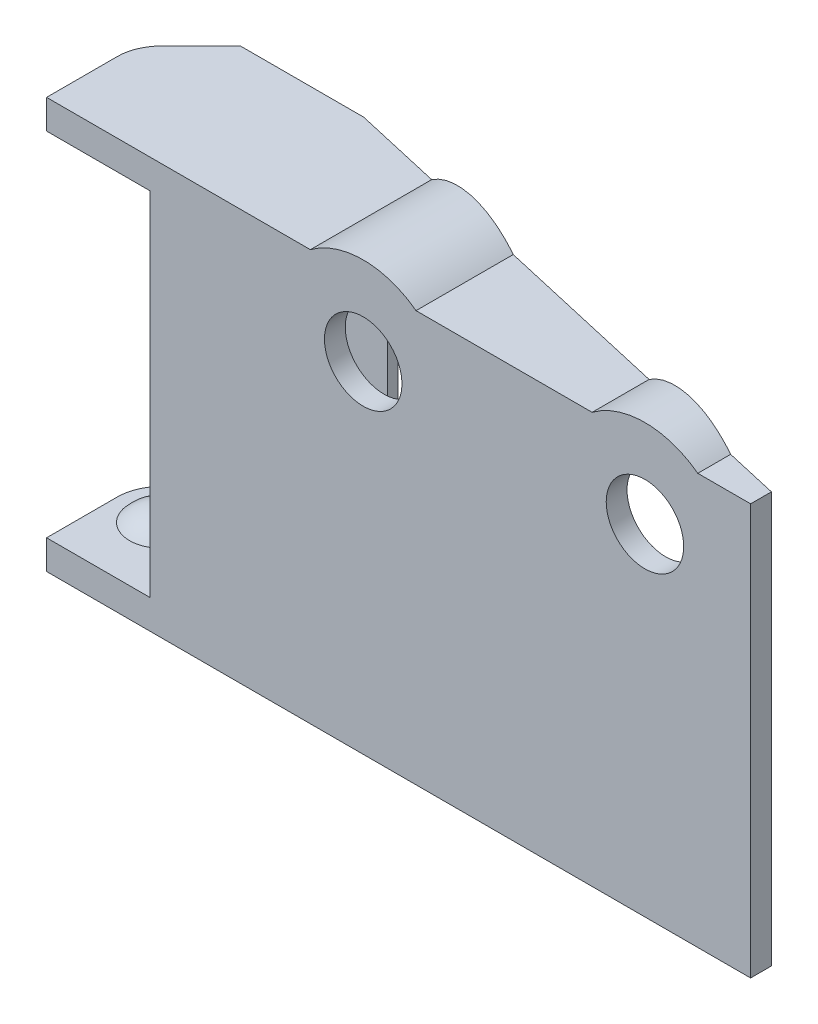
from build123d import *

# Parameters (mm, degrees)
BOSS_EXTRUDE2_DEPTH             = 2.1082
BOSS_EXTRUDE3_DEPTH             = 0.9
SKETCH13_W                      = 5.200208993
SKETCH13_H                      = 1.5
BOSS_EXTRUDE4_DEPTH             = 12.7
SKETCH16_W                      = 7.09322036
SKETCH16_H                      = 1.5
BOSS_EXTRUDE5_DEPTH             = 11.8
SKETCH17_W                      = 1.5
SKETCH17_H                      = 23.6
BOSS_EXTRUDE6_DEPTH             = 38.1
BOSS_EXTRUDE7_REACH             = 53.45
BOSS_EXTRUDE8_DEPTH             = 3.0082
CUT_EXTRUDE1_DEPTH              = 52.450131959
CUT_EXTRUDE2_REACH              = 52.338
SKETCH21_R                      = 2.794
SKETCH22_R                      = 4.572
CUT_EXTRUDE3_DEPTH              = 51.337641034
BOSS_EXTRUDE9_REACH             = 52.338
BOSS_EXTRUDE9_DIRECTION_2_DEPTH = 1.5


with BuildPart() as part:
    # Sketch6 → Boss-Extrude2 (new body)
    with BuildSketch(Plane(origin=(0, 0, 0), x_dir=(1, 0, 0), z_dir=(0, 1, 0))):
        with BuildLine():
            Line((3.1496, 3.175), (3.1496, 8.27377964))
            Line((3.1496, 8.27377964), (-5.741348421, 8.27377964))
            Line((-5.741348421, 8.27377964), (-8.59506403, 5.42006403))
            ThreePointArc((-8.59506403, 5.42006403), (-9.283317516, 4.390019898), (-9.525, 3.175))
            Line((-9.525, 3.175), (-9.525, -1.92377964))
            Line((-9.525, -1.92377964), (-6.989909723, -1.92377964))
            Line((-6.989909723, -1.92377964), (3.1496, -1.92377964))
            Line((3.1496, -1.92377964), (3.1496, 3.175))
        make_face()
    extrude(amount=BOSS_EXTRUDE2_DEPTH)

    # Sketch7 → Boss-Extrude3 (add)
    with BuildSketch(Plane.XZ):
        with BuildLine():
            Line((-2.050608993, 1.92377964), (-2.050608993, 0.42377964))
            ThreePointArc((-2.050608993, 0.42377964), (-0.881374643, -4.411978027), (-4.017957094, -8.27377964))
            Line((-4.017957094, -8.27377964), (6.35, -8.27377964))
            ThreePointArc((6.35, -8.27377964), (11.44877964, -3.175), (6.35, 1.92377964))
            Line((6.35, 1.92377964), (-2.050608993, 1.92377964))
        make_face()
    extrude(amount=BOSS_EXTRUDE3_DEPTH)

    # Sketch10 → Revolve2 (revolve)
    with BuildSketch(Plane.XY.offset(-3.175), mode=Mode.PRIVATE) as revolve2_sk:
        with BuildLine():
            Line((-6.35, 0), (-6.35, -1.065979307))
            ThreePointArc((-6.35, -1.065979307), (-5.088839039, -0.786386653), (-4.064, 0))
            Line((-4.064, 0), (-6.35, 0))
        make_face()
    revolve(revolve2_sk.sketch.rotate(Axis((-6.35, 0, -3.175), (0, -1, 0)), 180), axis=Axis((-6.35, 0, -3.175), (0, -1, 0)))

    # Sketch13 → Boss-Extrude4 (add)
    with BuildSketch(Plane.XZ):
        with Locations((0.549495504, 1.17377964)):
            Rectangle(SKETCH13_W, SKETCH13_H)
    extrude(amount=BOSS_EXTRUDE4_DEPTH)

    # Sketch16 → Boss-Extrude5 (add)
    with BuildSketch(Plane.XZ.offset(0.9)):
        with Locations((2.80338982, -7.52377964)):
            Rectangle(SKETCH16_W, SKETCH16_H)
    extrude(amount=BOSS_EXTRUDE5_DEPTH)

    # Mirror1: part across plane


with BuildPart() as part_1:
    add(part.part)
    add(part.part.mirror(Plane(origin=(3.1496, -12.7, 1.92377964), x_dir=(0, 0, 1), z_dir=(0, 1, 0))))

    # Sketch17 → Boss-Extrude6 (add)
    with BuildSketch(Plane(origin=(3.1496, 0, 0), x_dir=(0, 0, -1), z_dir=(1, 0, 0))):
        with Locations((-1.17377964, -12.7)):
            Rectangle(SKETCH17_W, SKETCH17_H)
    extrude(amount=BOSS_EXTRUDE6_DEPTH)

    # Boss-Extrude7: up to this face of the body (flat: up to its plane)
    boss_extrude7_end = Plane(part_1.part.faces().sort_by_distance((25.033512305, -24.5, 1.184664169))[0])
    # Sketch18 → Boss-Extrude7 (add, up to the picked face)
    with BuildSketch(Plane.XZ.offset(27.5082), mode=Mode.PRIVATE) as boss_extrude7_sk1:
        Polygon((3.1496, -8.27377964), (41.2496, 0.42377964), (41.2496, 1.92377964), (3.1496, 1.92377964), align=None)
    boss_extrude7_tool1 = split(extrude(boss_extrude7_sk1.sketch, amount=-BOSS_EXTRUDE7_REACH, mode=Mode.PRIVATE), bisect_by=boss_extrude7_end, keep=Keep.BOTH, mode=Mode.PRIVATE)
    add(boss_extrude7_tool1.solids().sort_by(Axis((17.478145, -27.5082, -1.539523), (0, 1, 0)))[0])

    # Sketch19 → Boss-Extrude8 (add)
    with BuildSketch(Plane(origin=(0, 2.1082, 0), x_dir=(1, 0, 0), z_dir=(0, 1, 0))):
        Polygon((3.1496, 8.27377964), (41.2496, -0.42377964), (41.2496, -1.92377964), (3.1496, -1.92377964), align=None)
    extrude(amount=-BOSS_EXTRUDE8_DEPTH)

    # Sketch20 → Cut-Extrude1 (cut, through all)
    with BuildSketch(Plane.XZ.offset(27.5082)):
        with BuildLine():
            Line((10.03132609, -6.702802721), (3.1496, -8.27377964))
            Line((3.1496, -8.27377964), (6.35, -8.27377964))
            ThreePointArc((6.35, -8.27377964), (8.351257746, -7.864618455), (10.03132609, -6.702802721))
        make_face()
    extrude(amount=-CUT_EXTRUDE1_DEPTH, mode=Mode.SUBTRACT)

    # Sketch21 → Cut-Extrude2 (cut, up to next)
    with BuildSketch(Plane(origin=(0, 0, 0.42377964), x_dir=(-1, 0, 0), z_dir=(0, 0, -1)), mode=Mode.PRIVATE) as cut_extrude2_sk1:
        with Locations((-33.6296, -2.9718)):
            Circle(SKETCH21_R)
    cut_extrude2_tool1 = extrude(cut_extrude2_sk1.sketch, amount=-CUT_EXTRUDE2_REACH, mode=Mode.PRIVATE) & part_1.part
    # Sketch21 → Cut-Extrude2 (cut, up to next)
    with BuildSketch(Plane(origin=(0, 0, 0.42377964), x_dir=(-1, 0, 0), z_dir=(0, 0, -1)), mode=Mode.PRIVATE) as cut_extrude2_sk2:
        with Locations((-13.3096, -2.9718)):
            Circle(SKETCH21_R)
    cut_extrude2_tool2 = extrude(cut_extrude2_sk2.sketch, amount=-CUT_EXTRUDE2_REACH, mode=Mode.PRIVATE) & part_1.part
    add(cut_extrude2_tool1.solids().sort_by_distance((33.6296, -2.9718, 0.42378))[0], mode=Mode.SUBTRACT)
    add(cut_extrude2_tool2.solids().sort_by_distance((13.3096, -2.9718, 0.42378))[0], mode=Mode.SUBTRACT)

    # Sketch22 → Cut-Extrude3 (cut, through all)
    with BuildSketch(Plane(origin=(0, 0, 0.42377964), x_dir=(-1, 0, 0), z_dir=(0, 0, -1))):
        with Locations((-33.6296, -2.9718)):
            Circle(SKETCH22_R)
        with Locations((-13.3096, -2.9718)):
            Circle(SKETCH22_R)
    extrude(amount=CUT_EXTRUDE3_DEPTH, mode=Mode.SUBTRACT)

    # Boss-Extrude9: up to this plane
    boss_extrude9_end = Plane(origin=(3.1496, 14.941098048, -8.27377964), z_dir=(0.2225570001625305, 0, -0.9749196796037383))
    # Sketch23 → Boss-Extrude9 (add, up to the surface)
    with BuildSketch(Plane(origin=(0, 0, 0.42377964), x_dir=(-1, 0, 0), z_dir=(0, 0, -1)), mode=Mode.PRIVATE) as boss_extrude9_sk1:
        with BuildLine():
            ThreePointArc((-29.8196, 2.1082), (-33.6296, 3.3782), (-37.4396, 2.1082))
            Line((-37.4396, 2.1082), (-29.8196, 2.1082))
        make_face()
    boss_extrude9_tool1 = split(extrude(boss_extrude9_sk1.sketch, amount=BOSS_EXTRUDE9_REACH, mode=Mode.PRIVATE), bisect_by=boss_extrude9_end, keep=Keep.BOTH, mode=Mode.PRIVATE)
    add(boss_extrude9_tool1.solids().sort_by_distance((33.6296, 2.620823, 0.42378))[0])
    # Sketch23 → Boss-Extrude9 (add, up to the surface)
    with BuildSketch(Plane(origin=(0, 0, 0.42377964), x_dir=(-1, 0, 0), z_dir=(0, 0, -1)), mode=Mode.PRIVATE) as boss_extrude9_sk2:
        with BuildLine():
            ThreePointArc((-9.4996, 2.1082), (-13.3096, 3.3782), (-17.1196, 2.1082))
            Line((-17.1196, 2.1082), (-9.4996, 2.1082))
        make_face()
    boss_extrude9_tool2 = split(extrude(boss_extrude9_sk2.sketch, amount=BOSS_EXTRUDE9_REACH, mode=Mode.PRIVATE), bisect_by=boss_extrude9_end, keep=Keep.BOTH, mode=Mode.PRIVATE)
    add(boss_extrude9_tool2.solids().sort_by_distance((13.3096, 2.620823, 0.42378))[0])

    # Sketch23 → Boss-Extrude9 direction 2 (add)
    with BuildSketch(Plane(origin=(0, 0, 0.42377964), x_dir=(-1, 0, 0), z_dir=(0, 0, -1))):
        with BuildLine():
            ThreePointArc((-29.8196, 2.1082), (-33.6296, 3.3782), (-37.4396, 2.1082))
            Line((-37.4396, 2.1082), (-29.8196, 2.1082))
        make_face()
        with BuildLine():
            ThreePointArc((-9.4996, 2.1082), (-13.3096, 3.3782), (-17.1196, 2.1082))
            Line((-17.1196, 2.1082), (-9.4996, 2.1082))
        make_face()
    extrude(amount=-BOSS_EXTRUDE9_DIRECTION_2_DEPTH)


solid = part_1.part
